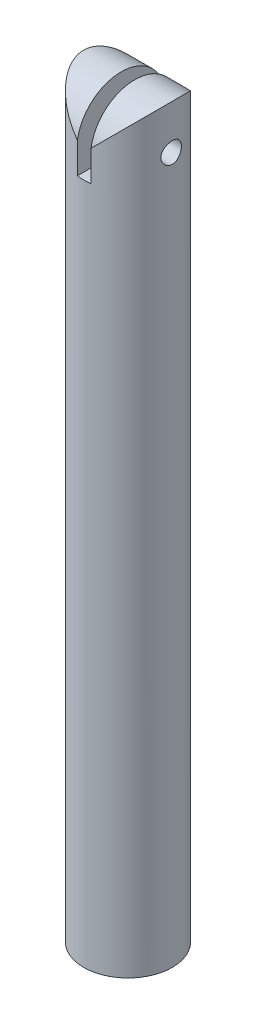
from build123d import *

# Parameters (mm, degrees)
SKETCH1_R               = 6.5
SKETCH1_R_2             = 2.5
BOSS_EXTRUDE1_DEPTH     = 100
SKETCH2_R               = 6.5
BOSS_EXTRUDE2_DEPTH     = 10
BOSS_EXTRUDE3_DEPTH     = 10
CUT_EXTRUDE2_DEPTH      = 7.5
CUT_EXTRUDE2_DEPTH_BACK = 7.5
SKETCH5_R               = 1.5
CUT_EXTRUDE3_DEPTH      = 8.5
CUT_EXTRUDE3_DEPTH_BACK = 6.5


with BuildPart() as part:
    # Sketch1 → Boss-Extrude1 (new body)
    with BuildSketch(Plane(origin=(0, 0, 0), x_dir=(1, 0, 0), z_dir=(0, 1, 0))):
        Circle(SKETCH1_R)
        Circle(SKETCH1_R_2, mode=Mode.SUBTRACT)
    extrude(amount=BOSS_EXTRUDE1_DEPTH)

    # Sketch2 → Boss-Extrude2 (add)
    with BuildSketch(Plane(origin=(0, 100, 0), x_dir=(1, 0, 0), z_dir=(0, 1, 0))):
        Circle(SKETCH2_R)
    extrude(amount=-BOSS_EXTRUDE2_DEPTH)

    # Sketch3 → Boss-Extrude3 (add)
    with BuildSketch(Plane(origin=(0, 100, 0), x_dir=(1, 0, 0), z_dir=(0, 1, 0))):
        with BuildLine():
            Line((-1, -6.422616), (-1, 6.422616))
            ThreePointArc((-1, 6.422616), (-6.5, 0), (-1, -6.422616))
        make_face()
        with BuildLine():
            Line((1, -6.422616), (1, 6.422616))
            ThreePointArc((1, 6.422616), (6.5, 0), (1, -6.422616))
        make_face()
    extrude(amount=BOSS_EXTRUDE3_DEPTH)

    # Sketch4 → Cut-Extrude2 (cut, two sides)
    with BuildSketch(Plane(origin=(0, 0, 0), x_dir=(0, 0, -1), z_dir=(1, 0, 0))) as cut_extrude2_sk:
        with BuildLine():
            ThreePointArc((0, 110), (4.541154, 108.150583), (6.498158, 103.654745))
            Line((6.498158, 103.654745), (6.422616, 110))
            Line((6.422616, 110), (0, 110))
        make_face()
        with BuildLine():
            Line((-6.422616, 110), (-6.498158, 103.654745))
            ThreePointArc((-6.498158, 103.654745), (-4.541154, 108.150583), (0, 110))
            Line((0, 110), (-6.422616, 110))
        make_face()
    extrude(amount=CUT_EXTRUDE2_DEPTH, mode=Mode.SUBTRACT)
    extrude(cut_extrude2_sk.sketch, amount=-CUT_EXTRUDE2_DEPTH_BACK, mode=Mode.SUBTRACT)

    # Sketch5 → Cut-Extrude3 (cut, two sides)
    with BuildSketch(Plane.ZY.offset(-1)) as cut_extrude3_sk:
        with Locations((0, 103.5)):
            Circle(SKETCH5_R)
    extrude(amount=CUT_EXTRUDE3_DEPTH, mode=Mode.SUBTRACT)
    extrude(cut_extrude3_sk.sketch, amount=-CUT_EXTRUDE3_DEPTH_BACK, mode=Mode.SUBTRACT)


solid = part.part
